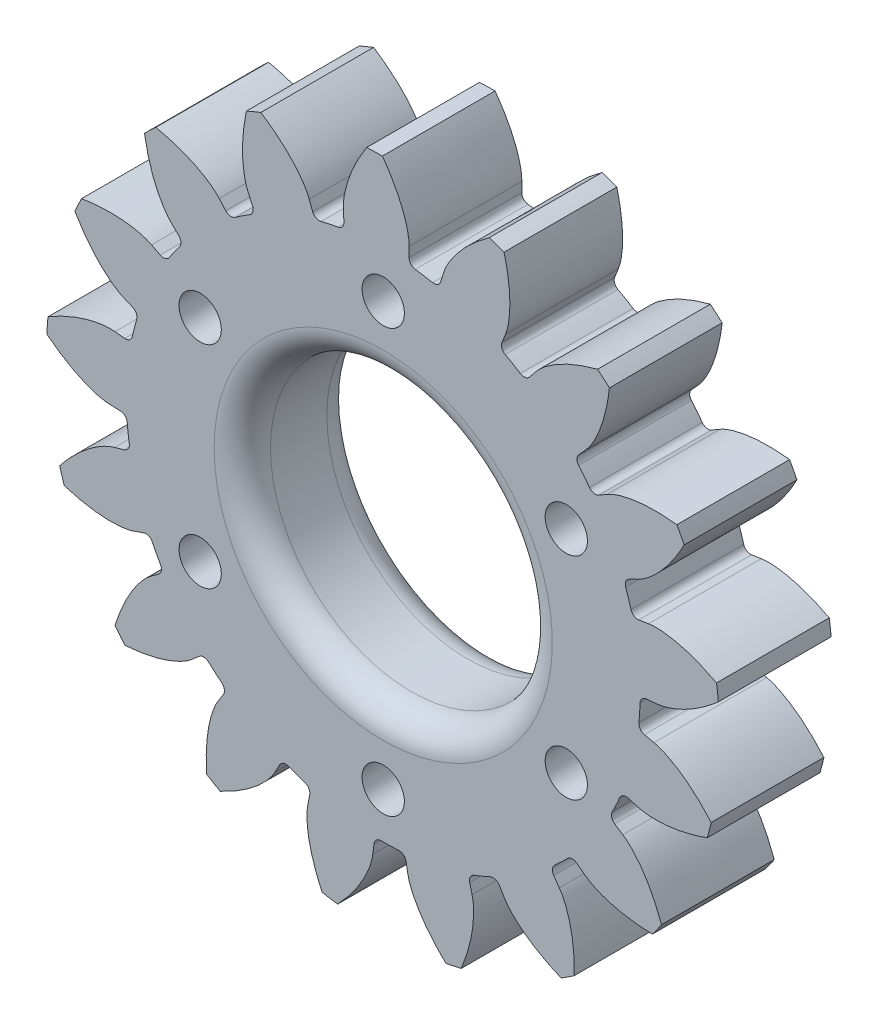
from build123d import *

# Parameters (mm, degrees)
SKETCH1_R           = 5
BOSS_EXTRUDE1_DEPTH = 4
SKETCH4_R           = 0.75
CUT_EXTRUDE1_DEPTH  = 5.0000001
FILLET1_R           = 1
FILLET2_R           = 1


with BuildPart() as part:
    # Sketch1 → Boss-Extrude1 (new body)
    with BuildSketch(Plane.XY):
        with BuildLine():
            Line((2.142690816, 9.446385822), (2.036760212, 9.116523343))
            ThreePointArc((2.036760212, 9.116523343), (1.925215556, 8.976884922), (1.749077663, 8.946610489))
            ThreePointArc((1.749077663, 8.946610489), (1.443445404, 9.000976463), (1.136139278, 9.044904613))
            ThreePointArc((1.136139278, 9.044904613), (0.978300237, 9.128737399), (0.916012393, 9.296252542))
            Line((0.916012393, 9.296252542), (0.918538131, 9.642697586))
            add(Edge.make_bspline(
                [(0.918538131, 9.642697586), (0.920074647, 9.853455045), (0.756738592, 10.686258414), (0.336577813, 11.434986659), (-0.030409782, 11.94504001)],
                knots=[0, 0, 0, 0, 0.250058326, 1, 1, 1, 1], degree=3))
            ThreePointArc((-0.030409782, 11.94504001), (-0.308005832, 11.941107068), (-0.585435504, 11.93072382))
            add(Edge.make_bspline(
                [(-0.585435504, 11.93072382), (-0.924729077, 11.407724954), (-1.308534817, 10.639195503), (-1.429406641, 9.798416791), (-1.414428472, 9.582521648)],
                knots=[-0.008484668, -0.008484668, -0.008484668, -0.008484668, 0.741457006, 1, 1, 1, 1], degree=3))
            Line((-1.414428472, 9.582521648), (-1.394045746, 9.236667499))
            ThreePointArc((-1.394045746, 9.236667499), (-1.447614825, 9.066163972), (-1.600922132, 8.974305558))
            ThreePointArc((-1.600922132, 8.974305558), (-1.905554981, 8.914593212), (-2.207978087, 8.844543215))
            ThreePointArc((-2.207978087, 8.844543215), (-2.385442505, 8.865696922), (-2.50403764, 8.999399176))
            Line((-2.50403764, 8.999399176), (-2.626832843, 9.32336196))
            add(Edge.make_bspline(
                [(-2.626832843, 9.32336196), (-2.701534461, 9.520442492), (-3.154684073, 10.238004717), (-3.81694417, 10.784393433), (-4.343402434, 11.127432808)],
                knots=[0, 0, 0, 0, 0.250058326, 1, 1, 1, 1], degree=3))
            ThreePointArc((-4.343402434, 11.127432808), (-4.600832298, 11.023486189), (-4.855776901, 10.913584942))
            add(Edge.make_bspline(
                [(-4.855776901, 10.913584942), (-4.983229754, 10.303336047), (-5.063493088, 9.448057053), (-4.872478404, 8.620390313), (-4.780521357, 8.424484826)],
                knots=[-0.008484668, -0.008484668, -0.008484668, -0.008484668, 0.741457006, 1, 1, 1, 1], degree=3))
            Line((-4.780521357, 8.424484826), (-4.636578102, 8.109348527))
            ThreePointArc((-4.636578102, 8.109348527), (-4.624936802, 7.93100734), (-4.734708522, 7.789970933))
            ThreePointArc((-4.734708522, 7.789970933), (-4.997199607, 7.62424475), (-5.253895777, 7.449677247))
            ThreePointArc((-5.253895777, 7.449677247), (-5.427018018, 7.405294949), (-5.585903513, 7.487127083))
            Line((-5.585903513, 7.487127083), (-5.817435487, 7.74485464))
            add(Edge.make_bspline(
                [(-5.817435487, 7.74485464), (-5.95828637, 7.901641426), (-6.640049173, 8.407051753), (-7.454966693, 8.677308116), (-8.069794519, 8.807004146)],
                knots=[0, 0, 0, 0, 0.250058326, 1, 1, 1, 1], degree=3))
            ThreePointArc((-8.069794519, 8.807004146), (-8.272290869, 8.617082417), (-8.470318721, 8.422505943))
            add(Edge.make_bspline(
                [(-8.470318721, 8.422505943), (-8.368717639, 7.807424515), (-8.13459856, 6.980906144), (-7.65749496, 6.278132356), (-7.500978342, 6.128674647)],
                knots=[-0.008484668, -0.008484668, -0.008484668, -0.008484668, 0.741457006, 1, 1, 1, 1], degree=3))
            Line((-7.500978342, 6.128674647), (-7.252914893, 5.886817101))
            ThreePointArc((-7.252914893, 5.886817101), (-7.177635437, 5.724724219), (-7.22904629, 5.553557567))
            ThreePointArc((-7.22904629, 5.553557567), (-7.413944735, 5.304199787), (-7.59024573, 5.048691086))
            ThreePointArc((-7.59024573, 5.048691086), (-7.735644677, 4.944766859), (-7.913362165, 4.963676991))
            Line((-7.913362165, 4.963676991), (-8.222361232, 5.120361784))
            add(Edge.make_bspline(
                [(-8.222361232, 5.120361784), (-8.410338689, 5.2156799), (-9.228638839, 5.440679864), (-10.086154654, 5.398304255), (-10.706316137, 5.297140773)],
                knots=[0, 0, 0, 0, 0.250058326, 1, 1, 1, 1], degree=3))
            ThreePointArc((-10.706316137, 5.297140773), (-10.826530719, 5.046893916), (-10.940897062, 4.793920846))
            add(Edge.make_bspline(
                [(-10.940897062, 4.793920846), (-10.623963835, 4.25707704), (-10.107081422, 3.570945177), (-9.40832439, 3.087977836), (-9.208386639, 3.005152997)],
                knots=[-0.008484668, -0.008484668, -0.008484668, -0.008484668, 0.741457006, 1, 1, 1, 1], degree=3))
            Line((-9.208386639, 3.005152997), (-8.889705338, 2.869238405))
            ThreePointArc((-8.889705338, 2.869238405), (-8.760954633, 2.745285371), (-8.7470613, 2.567105479))
            ThreePointArc((-8.7470613, 2.567105479), (-8.829395545, 2.267793252), (-8.901490937, 1.965851218))
            ThreePointArc((-8.901490937, 1.965851218), (-8.999529656, 1.816420605), (-9.172077407, 1.769854816))
            Line((-9.172077407, 1.769854816), (-9.516811531, 1.804335697))
            add(Edge.make_bspline(
                [(-9.516811531, 1.804335697), (-9.726528165, 1.825311903), (-10.570849691, 1.739514011), (-11.35515154, 1.390229491), (-11.896890436, 1.071869186)],
                knots=[0, 0, 0, 0, 0.250058326, 1, 1, 1, 1], degree=3))
            ThreePointArc((-11.896890436, 1.071869186), (-11.918587603, 0.795094426), (-11.933846629, 0.517890175))
            add(Edge.make_bspline(
                [(-11.933846629, 0.517890175), (-11.444384845, 0.131787721), (-10.714546932, -0.321291723), (-9.888507478, -0.519225201), (-9.672151294, -0.524231217)],
                knots=[-0.008484668, -0.008484668, -0.008484668, -0.008484668, 0.741457006, 1, 1, 1, 1], degree=3))
            Line((-9.672151294, -0.524231217), (-9.325891817, -0.535846836))
            ThreePointArc((-9.325891817, -0.535846836), (-9.16105836, -0.604919479), (-9.083737211, -0.766048429))
            ThreePointArc((-9.083737211, -0.766048429), (-9.052387561, -1.074891329), (-9.010540469, -1.382487749))
            ThreePointArc((-9.010540469, -1.382487749), (-9.047978288, -1.557243317), (-9.19205277, -1.662996058))
            Line((-9.19205277, -1.662996058), (-9.525963699, -1.755375925))
            add(Edge.make_bspline(
                [(-9.525963699, -1.755375925), (-9.729096116, -1.811574581), (-10.485408718, -2.196582847), (-11.090572289, -2.805603469), (-11.480723759, -3.298164274)],
                knots=[0, 0, 0, 0, 0.250058326, 1, 1, 1, 1], degree=3))
            ThreePointArc((-11.480723759, -3.298164274), (-11.400973189, -3.564086973), (-11.315064081, -3.828084435))
            add(Edge.make_bspline(
                [(-11.315064081, -3.828084435), (-10.719178266, -4.01130026), (-9.874953507, -4.170136395), (-9.033192836, -4.056303998), (-8.829638322, -3.982815101)],
                knots=[-0.008484668, -0.008484668, -0.008484668, -0.008484668, 0.741457006, 1, 1, 1, 1], degree=3))
            Line((-8.829638322, -3.982815101), (-8.50256493, -3.868562992))
            ThreePointArc((-8.50256493, -3.868562992), (-8.323910392, -3.873426601), (-8.193604078, -3.995743252))
            ThreePointArc((-8.193604078, -3.995743252), (-8.052804476, -4.272405879), (-7.902666581, -4.544114086))
            ThreePointArc((-7.902666581, -4.544114086), (-7.874447315, -4.7205929), (-7.970590473, -4.8712501))
            Line((-7.970590473, -4.8712501), (-8.248581684, -5.078014301))
            add(Edge.make_bspline(
                [(-8.248581684, -5.078014301), (-8.417695725, -5.20379788), (-8.983855196, -5.836019021), (-9.328149796, -6.622524135), (-9.514021721, -7.222762373)],
                knots=[0, 0, 0, 0, 0.250058326, 1, 1, 1, 1], degree=3))
            ThreePointArc((-9.514021721, -7.222762373), (-9.34359417, -7.441918676), (-9.16811943, -7.657055029))
            add(Edge.make_bspline(
                [(-9.16811943, -7.657055029), (-8.546287266, -7.612639914), (-7.701692893, -7.45578104), (-6.957895448, -7.045556464), (-6.794633768, -6.903497736)],
                knots=[-0.008484668, -0.008484668, -0.008484668, -0.008484668, 0.741457006, 1, 1, 1, 1], degree=3))
            Line((-6.794633768, -6.903497736), (-6.530919535, -6.678808281))
            ThreePointArc((-6.530919535, -6.678808281), (-6.362572202, -6.618805997), (-6.196879311, -6.685790808))
            ThreePointArc((-6.196879311, -6.685790808), (-5.965645524, -6.892908341), (-5.727493781, -7.092032636))
            ThreePointArc((-5.727493781, -7.092032636), (-5.637428599, -7.246400254), (-5.672655765, -7.421614824))
            Line((-5.672655765, -7.421614824), (-5.857183005, -7.714838707))
            add(Edge.make_bspline(
                [(-5.857183005, -7.714838707), (-5.969438883, -7.893219439), (-6.268982248, -8.687268487), (-6.305908984, -9.545036219), (-6.26239833, -10.171886391)],
                knots=[0, 0, 0, 0, 0.250058326, 1, 1, 1, 1], degree=3))
            ThreePointArc((-6.26239833, -10.171886391), (-6.024310985, -10.314678025), (-5.782969448, -10.451897912))
            add(Edge.make_bspline(
                [(-5.782969448, -10.451897912), (-5.219172814, -10.185850364), (-4.488275976, -9.734481141), (-3.942895724, -9.083267488), (-3.841976273, -8.891824748)],
                knots=[-0.008484668, -0.008484668, -0.008484668, -0.008484668, 0.741457006, 1, 1, 1, 1], degree=3))
            Line((-3.841976273, -8.891824748), (-3.677237268, -8.587043502))
            ThreePointArc((-3.677237268, -8.587043502), (-3.541933379, -8.470278967), (-3.363231656, -8.472885267))
            ThreePointArc((-3.363231656, -8.472885267), (-3.072793087, -8.582485337), (-2.778791209, -8.682132879))
            ThreePointArc((-2.778791209, -8.682132879), (-2.639043912, -8.7935411), (-2.608597463, -8.969649341))
            Line((-2.608597463, -8.969649341), (-2.674739306, -9.309731396))
            add(Edge.make_bspline(
                [(-2.674739306, -9.309731396), (-2.714976241, -9.516617976), (-2.70744851, -10.365254206), (-2.432020221, -11.178438271), (-2.165003344, -11.747240788)],
                knots=[0, 0, 0, 0, 0.250058326, 1, 1, 1, 1], degree=3))
            ThreePointArc((-2.165003344, -11.747240788), (-1.891411218, -11.794382951), (-1.616797397, -11.835154067))
            add(Edge.make_bspline(
                [(-1.616797397, -11.835154067), (-1.187180152, -11.38340528), (-0.668692519, -10.698485624), (-0.395386084, -9.894232906), (-0.370438593, -9.679261556)],
                knots=[-0.008484668, -0.008484668, -0.008484668, -0.008484668, 0.741457006, 1, 1, 1, 1], degree=3))
            Line((-0.370438593, -9.679261556), (-0.326923731, -9.335550916))
            ThreePointArc((-0.326923731, -9.335550916), (-0.242936827, -9.177793828), (-0.075360929, -9.115669622))
            ThreePointArc((-0.075360929, -9.115669622), (0.235057082, -9.112950131), (0.545202514, -9.099662968))
            ThreePointArc((0.545202514, -9.099662968), (0.715758279, -9.153065494), (0.807766381, -9.306283012))
            Line((0.807766381, -9.306283012), (0.868942758, -9.647293274))
            add(Edge.make_bspline(
                [(0.868942758, -9.647293274), (0.906158986, -9.854744521), (1.219741152, -10.643354909), (1.770326349, -11.302130292), (2.22478734, -11.736065222)],
                knots=[0, 0, 0, 0, 0.250058326, 1, 1, 1, 1], degree=3))
            ThreePointArc((2.22478734, -11.736065222), (2.496934113, -11.681191105), (2.767732101, -11.620007083))
            add(Edge.make_bspline(
                [(2.767732101, -11.620007083), (3.005147767, -11.043568236), (3.241201568, -10.217600341), (3.205522637, -9.368927344), (3.151128871, -9.159460457)],
                knots=[-0.008484668, -0.008484668, -0.008484668, -0.008484668, 0.741457006, 1, 1, 1, 1], degree=3))
            Line((3.151128871, -9.159460457), (3.067542667, -8.823240448))
            ThreePointArc((3.067542667, -8.823240448), (3.08886969, -8.645796776), (3.222687709, -8.527332282))
            ThreePointArc((3.222687709, -8.527332282), (3.511161491, -8.412660513), (3.795563616, -8.288233151))
            ThreePointArc((3.795563616, -8.288233151), (3.973893348, -8.276417674), (4.115036899, -8.386051594))
            Line((4.115036899, -8.386051594), (4.295269287, -8.681934737))
            add(Edge.make_bspline(
                [(4.295269287, -8.681934737), (4.40491242, -8.861933212), (4.982198012, -9.484011554), (5.733580536, -9.899406991), (6.314108166, -10.139869016)],
                knots=[0, 0, 0, 0, 0.250058326, 1, 1, 1, 1], degree=3))
            ThreePointArc((6.314108166, -10.139869016), (6.548054657, -9.990389672), (6.778464043, -9.835513755))
            add(Edge.make_bspline(
                [(6.778464043, -9.835513755), (6.791613828, -9.212236107), (6.713353424, -8.356771514), (6.373507764, -7.578296229), (6.247118921, -7.402623469)],
                knots=[-0.008484668, -0.008484668, -0.008484668, -0.008484668, 0.741457006, 1, 1, 1, 1], degree=3))
            Line((6.247118921, -7.402623469), (6.047720431, -7.119302467))
            ThreePointArc((6.047720431, -7.119302467), (6.003507239, -6.946136961), (6.085494515, -6.787331466))
            ThreePointArc((6.085494515, -6.787331466), (6.313064084, -6.576194476), (6.53331282, -6.357431519))
            ThreePointArc((6.53331282, -6.357431519), (6.6953321, -6.281993786), (6.866548882, -6.33323744))
            Line((6.866548882, -6.33323744), (7.141495898, -6.544032806))
            add(Edge.make_bspline(
                [(7.141495898, -6.544032806), (7.308758024, -6.672268717), (8.071781424, -7.043799887), (8.9224829, -7.159713921), (9.550673697, -7.174227313)],
                knots=[0, 0, 0, 0, 0.250058326, 1, 1, 1, 1], degree=3))
            ThreePointArc((9.550673697, -7.174227313), (9.714824136, -6.950330756), (9.873726855, -6.722679793))
            add(Edge.make_bspline(
                [(9.873726855, -6.722679793), (9.660834808, -6.136740445), (9.278829699, -5.367314387), (8.68071535, -4.764174216), (8.499400943, -4.646021162)],
                knots=[-0.008484668, -0.008484668, -0.008484668, -0.008484668, 0.741457006, 1, 1, 1, 1], degree=3))
            Line((8.499400943, -4.646021162), (8.211120038, -4.453863238))
            ThreePointArc((8.211120038, -4.453863238), (8.107337868, -4.30836286), (8.126421565, -4.130663926))
            ThreePointArc((8.126421565, -4.130663926), (8.262352391, -3.851576936), (8.388701925, -3.568023533))
            ThreePointArc((8.388701925, -3.568023533), (8.512529152, -3.439151827), (8.69069539, -3.425084476))
            Line((8.69069539, -3.425084476), (9.023223916, -3.522322983))
            add(Edge.make_bspline(
                [(9.023223916, -3.522322983), (9.225515358, -3.58147736), (10.071226027, -3.652284013), (10.906354508, -3.453061812), (11.497367823, -3.239666457)],
                knots=[0, 0, 0, 0, 0.250058326, 1, 1, 1, 1], degree=3))
            ThreePointArc((11.497367823, -3.239666457), (11.569552783, -2.971591157), (11.635488142, -2.701910674))
            add(Edge.make_bspline(
                [(11.635488142, -2.701910674), (11.225306515, -2.232443981), (10.591148608, -1.652971712), (9.815544227, -1.306624075), (9.603791772, -1.261947952)],
                knots=[-0.008484668, -0.008484668, -0.008484668, -0.008484668, 0.741457006, 1, 1, 1, 1], degree=3))
            Line((9.603791772, -1.261947952), (9.265562385, -1.186905099))
            ThreePointArc((9.265562385, -1.186905099), (9.116227595, -1.088720481), (9.069830353, -0.916127333))
            ThreePointArc((9.069830353, -0.916127333), (9.095764224, -0.606782588), (9.111150352, -0.296734198))
            ThreePointArc((9.111150352, -0.296734198), (9.180061972, -0.131833357), (9.341115328, -0.054354874))
            Line((9.341115328, -0.054354874), (9.686315544, -0.024903923))
            add(Edge.make_bspline(
                [(9.686315544, -0.024903923), (9.896315722, -0.006987639), (10.710495748, 0.232493054), (11.417262505, 0.719945428), (11.891278715, 1.132429305)],
                knots=[0, 0, 0, 0, 0.250058326, 1, 1, 1, 1], degree=3))
            ThreePointArc((11.891278715, 1.132429305), (11.861749218, 1.408478293), (11.825812282, 1.683766454))
            add(Edge.make_bspline(
                [(11.825812282, 1.683766454), (11.273738375, 1.973356413), (10.47307421, 2.284613953), (9.624729466, 2.327392886), (9.411137305, 2.292558321)],
                knots=[-0.008484668, -0.008484668, -0.008484668, -0.008484668, 0.741457006, 1, 1, 1, 1], degree=3))
            Line((9.411137305, 2.292558321), (9.068639189, 2.24035115))
            ThreePointArc((9.068639189, 2.24035115), (8.89392027, 2.277959631), (8.788308294, 2.422137332))
            ThreePointArc((8.788308294, 2.422137332), (8.700742697, 2.719961111), (8.603087437, 3.014630735))
            ThreePointArc((8.603087437, 3.014630735), (8.607776555, 3.193289938), (8.72996588, 3.323715655))
            Line((8.72996588, 3.323715655), (9.041216585, 3.47587855))
            add(Edge.make_bspline(
                [(9.041216585, 3.47587855), (9.23056381, 3.568445801), (9.90325367, 4.085870646), (10.386205936, 4.795720049), (10.679206525, 5.351584215)],
                knots=[0, 0, 0, 0, 0.250058326, 1, 1, 1, 1], degree=3))
            ThreePointArc((10.679206525, 5.351584215), (10.551950692, 5.598324945), (10.418994944, 5.842041592))
            add(Edge.make_bspline(
                [(10.418994944, 5.842041592), (9.799589398, 5.912644088), (8.940553107, 5.913649844), (8.134041659, 5.647082543), (7.947456596, 5.537441889)],
                knots=[-0.008484668, -0.008484668, -0.008484668, -0.008484668, 0.741457006, 1, 1, 1, 1], degree=3))
            Line((7.947456596, 5.537441889), (7.64694602, 5.365035562))
            ThreePointArc((7.64694602, 5.365035562), (7.470439729, 5.336988673), (7.319876502, 5.433278929))
            ThreePointArc((7.319876502, 5.433278929), (7.130637656, 5.67935899), (6.933129893, 5.918853082))
            ThreePointArc((6.933129893, 5.918853082), (6.872963217, 6.087141733), (6.939786166, 6.252899967))
            Line((6.939786166, 6.252899967), (7.175051226, 6.507224364))
            add(Edge.make_bspline(
                [(7.175051226, 6.507224364), (7.318173108, 6.661940862), (7.758522308, 7.387428767), (7.952434703, 8.223806103), (8.024848318, 8.847978022)],
                knots=[0, 0, 0, 0, 0.250058326, 1, 1, 1, 1], degree=3))
            ThreePointArc((8.024848318, 8.847978022), (7.817052756, 9.032086792), (7.605034605, 9.211316641))
            add(Edge.make_bspline(
                [(7.605034605, 9.211316641), (7.001951571, 9.053396417), (6.200560765, 8.744014555), (5.544806453, 8.20410241), (5.410427836, 8.034463247)],
                knots=[-0.008484668, -0.008484668, -0.008484668, -0.008484668, 0.741457006, 1, 1, 1, 1], degree=3))
            Line((5.410427836, 8.034463247), (5.192490418, 7.765142193))
            ThreePointArc((5.192490418, 7.765142193), (5.038034908, 7.675227821), (4.862854828, 7.710626099))
            ThreePointArc((4.862854828, 7.710626099), (4.597500488, 7.871727967), (4.326814738, 8.023701524))
            ThreePointArc((4.326814738, 8.023701524), (4.209918111, 8.158891306), (4.212349875, 8.33759549))
            Line((4.212349875, 8.33759549), (4.339855442, 8.65973347))
            add(Edge.make_bspline(
                [(4.339855442, 8.65973347), (4.417422576, 8.855703895), (4.565959517, 9.691273698), (4.444643097, 10.541221574), (4.286689878, 11.149403369)],
                knots=[0, 0, 0, 0, 0.250058326, 1, 1, 1, 1], degree=3))
            ThreePointArc((4.286689878, 11.149403369), (4.026418528, 11.246015269), (3.763972202, 11.336552336))
            add(Edge.make_bspline(
                [(3.763972202, 11.336552336), (3.258661385, 10.971437393), (2.623148333, 10.393451648), (2.206714411, 9.653112786), (2.142690816, 9.446385822)],
                knots=[-0.008484668, -0.008484668, -0.008484668, -0.008484668, 0.741457006, 1, 1, 1, 1], degree=3))
        make_face()
        Circle(SKETCH1_R, mode=Mode.SUBTRACT)
    extrude(amount=BOSS_EXTRUDE1_DEPTH)

    # Sketch4 → Cut-Extrude1 (cut, through all)
    with BuildSketch(Plane.XY.offset(4)):
        with Locations((0, 7.5)):
            Circle(SKETCH4_R)
        with Locations((6.495190528, 3.75)):
            Circle(SKETCH4_R)
        with Locations((6.495190528, -3.75)):
            Circle(SKETCH4_R)
        with Locations((0, -7.5)):
            Circle(SKETCH4_R)
        with Locations((-6.495190528, -3.75)):
            Circle(SKETCH4_R)
        with Locations((-6.495190528, 3.75)):
            Circle(SKETCH4_R)
    extrude(amount=-CUT_EXTRUDE1_DEPTH, mode=Mode.SUBTRACT)

    # Fillet1
    fillet1_edges = [part.edges().sort_by_distance(p)[0] for p in [
        (-5, 0, 4),
    ]]
    fillet(fillet1_edges, radius=FILLET1_R)

    # Fillet2
    fillet2_edges = [part.edges().sort_by_distance(p)[0] for p in [
        (-5, 0, 0),
    ]]
    fillet(fillet2_edges, radius=FILLET2_R)


solid = part.part
